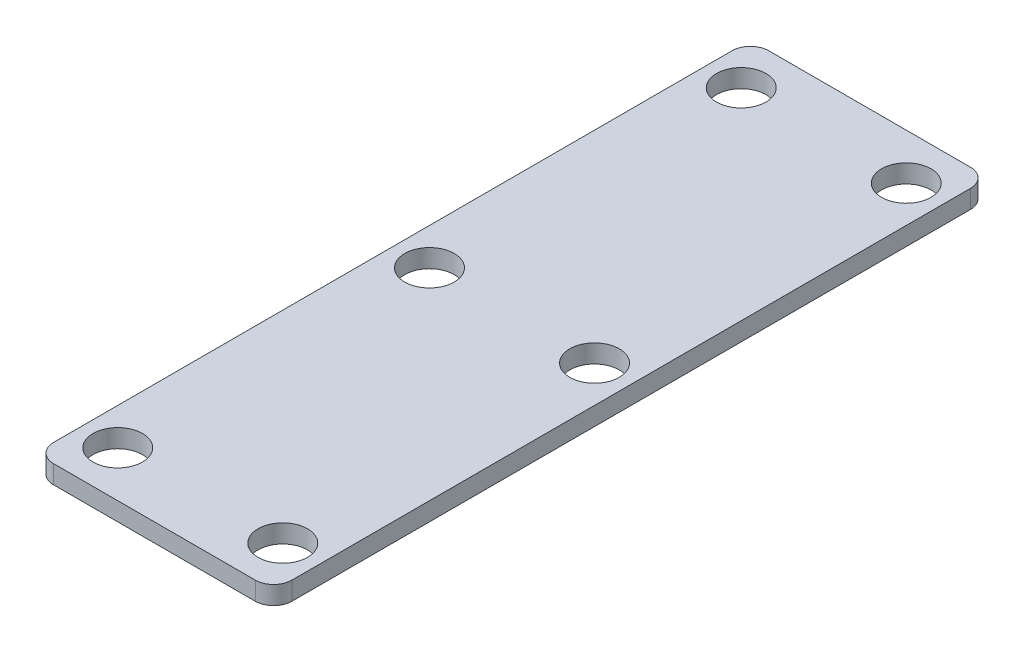
from build123d import *

# Parameters (mm, degrees)
SKETCH1_W           = 13
SKETCH1_H           = 39
BOSS_EXTRUDE1_DEPTH = 1
SKETCH2_R           = 1.35
CUT_EXTRUDE1_DEPTH  = 2
FILLET1_R           = 1


with BuildPart() as part:
    # Sketch1 → Boss-Extrude1 (new body)
    with BuildSketch(Plane(origin=(0, 0, 0), x_dir=(1, 0, 0), z_dir=(0, 1, 0))):
        Rectangle(SKETCH1_W, SKETCH1_H)
    extrude(amount=BOSS_EXTRUDE1_DEPTH)

    # Sketch2 → Cut-Extrude1 (cut, through all)
    with BuildSketch(Plane(origin=(0, 1, 0), x_dir=(1, 0, 0), z_dir=(0, 1, 0))):
        with Locations((4.5, 0)):
            Circle(SKETCH2_R)
        with Locations((4.5, -17)):
            Circle(SKETCH2_R)
        with Locations((4.5, 17)):
            Circle(SKETCH2_R)
        with Locations((-4.5, 0)):
            Circle(SKETCH2_R)
        with Locations((-4.5, 17)):
            Circle(SKETCH2_R)
        with Locations((-4.5, -17)):
            Circle(SKETCH2_R)
    extrude(amount=-CUT_EXTRUDE1_DEPTH, mode=Mode.SUBTRACT)

    # Fillet1
    fillet1_edges = [part.edges().sort_by_distance(p)[0] for p in [
        (6.5, 0.5, 19.5),
        (-6.5, 0.5, 19.5),
        (-6.5, 0.5, -19.5),
        (6.5, 0.5, -19.5),
    ]]
    fillet(fillet1_edges, radius=FILLET1_R)


solid = part.part
